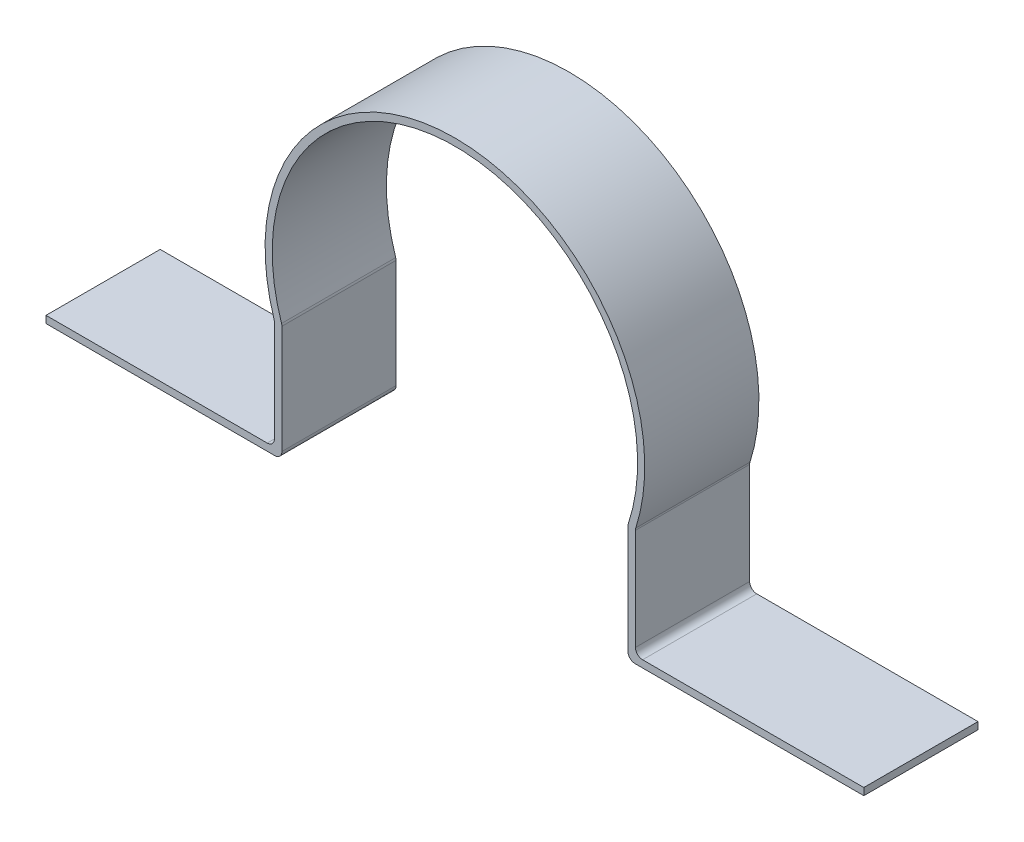
from build123d import *

# Parameters (mm, degrees)
BOSS_EXTRUDE2_DEPTH = 12.7
FILLET2_R           = 0.79375


with BuildPart() as part:
    # Sketch1 → Boss-Extrude2 (new body)
    with BuildSketch(Plane.XY):
        with BuildLine():
            Line((20.080431402, -6.524317111), (20.080431402, -18.716317111))
            Line((20.080431402, -18.716317111), (45.480431402, -18.716317111))
            Line((45.480431402, -18.716317111), (45.480431402, -19.510067111))
            Line((45.480431402, -19.510067111), (19.244107832, -19.510067111))
            Line((19.244107832, -19.510067111), (19.244107832, -18.721996551))
            Line((19.244107832, -18.721996551), (19.244107832, -6.524317111))
            ThreePointArc((19.244107832, -6.524317111), (0, 20.32), (-19.244107832, -6.524317111))
            Line((-19.244107832, -6.524317111), (-20.080431402, -6.524317111))
            ThreePointArc((-20.080431402, -6.524317111), (0, 21.11375), (20.080431402, -6.524317111))
        make_face()
        Polygon((-19.244107832, -6.524317111), (-19.244107832, -18.721996551), (-19.244107832, -19.510067111), (-45.480431402, -19.510067111), (-45.480431402, -18.716317111), (-20.080431402, -18.716317111), (-20.080431402, -6.524317111), align=None)
    extrude(amount=BOSS_EXTRUDE2_DEPTH)

    # Fillet2
    fillet2_edges = [part.edges().sort_by_distance(p)[0] for p in [
        (20.080431402, -18.716317111, 6.35),
        (19.244107832, -19.510067111, 6.35),
        (19.244107832, -6.524317111, 6.35),
        (-19.244107832, -6.524317111, 6.35),
        (-19.244107832, -19.510067111, 6.35),
        (-20.080431402, -18.716317111, 6.35),
        (-20.080431402, -6.524317111, 6.35),
        (20.080431402, -6.524317111, 6.35),
    ]]
    fillet(fillet2_edges, radius=FILLET2_R)


solid = part.part
